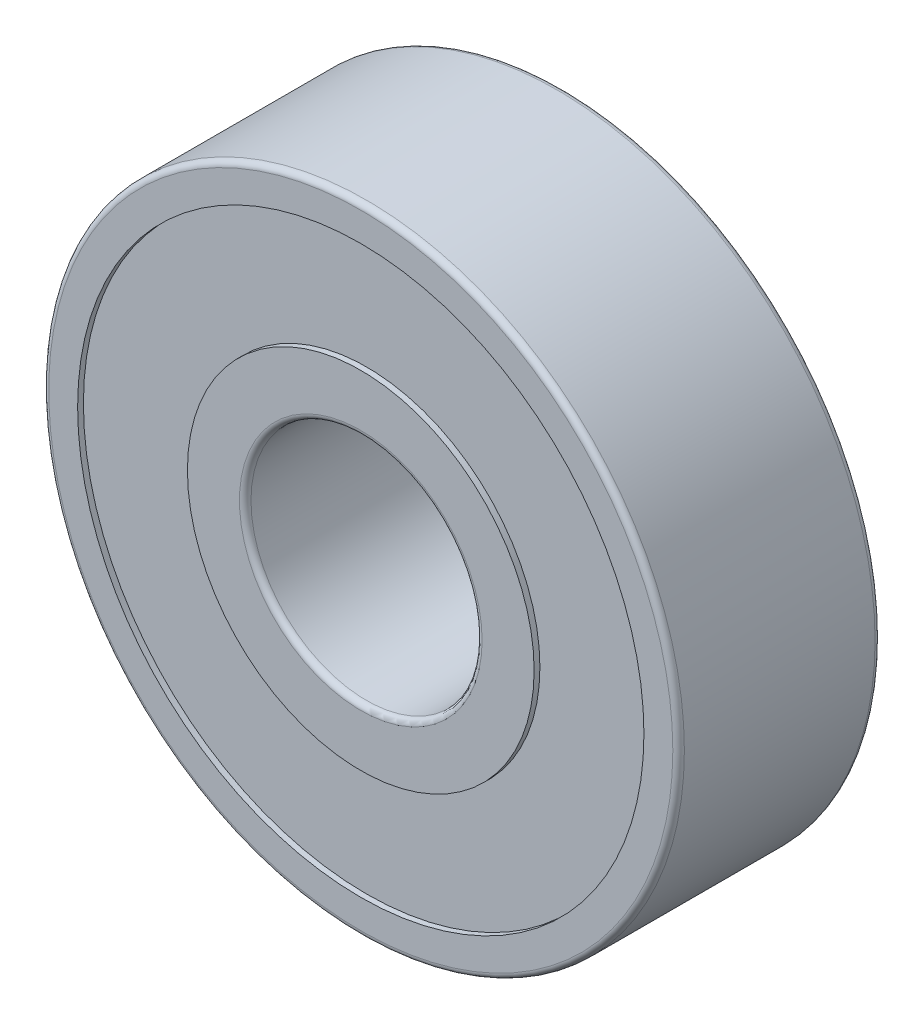
from build123d import *

# Parameters (mm, degrees)
SKETCH1_R           = 11
SKETCH1_R_2         = 4
BOSS_EXTRUDE1_DEPTH = 7
SKETCH2_R           = 9.8
SKETCH2_R_2         = 6
CUT_EXTRUDE1_DEPTH  = 0.2
FILLET1_R           = 0.2


with BuildPart() as part:
    # Sketch1 → Boss-Extrude1 (new body)
    with BuildSketch(Plane.XY):
        Circle(SKETCH1_R)
        Circle(SKETCH1_R_2, mode=Mode.SUBTRACT)
    extrude(amount=BOSS_EXTRUDE1_DEPTH)

    # Sketch2 → Cut-Extrude1 (cut)
    with BuildSketch(Plane.XY.offset(7)):
        Circle(SKETCH2_R)
        Circle(SKETCH2_R_2, mode=Mode.SUBTRACT)
    cut_extrude1 = extrude(amount=-CUT_EXTRUDE1_DEPTH, mode=Mode.SUBTRACT)

    # Mirror1: Cut-Extrude1 across plane
    add(cut_extrude1.mirror(Plane.XY.offset(3.5)), mode=Mode.SUBTRACT)

    # Fillet1
    fillet1_edges = [part.edges().sort_by_distance(p)[0] for p in [
        (-11, 0, 0),
        (-11, 0, 7),
        (-4, 0, 0),
        (-4, 0, 7),
    ]]
    fillet(fillet1_edges, radius=FILLET1_R)


solid = part.part
